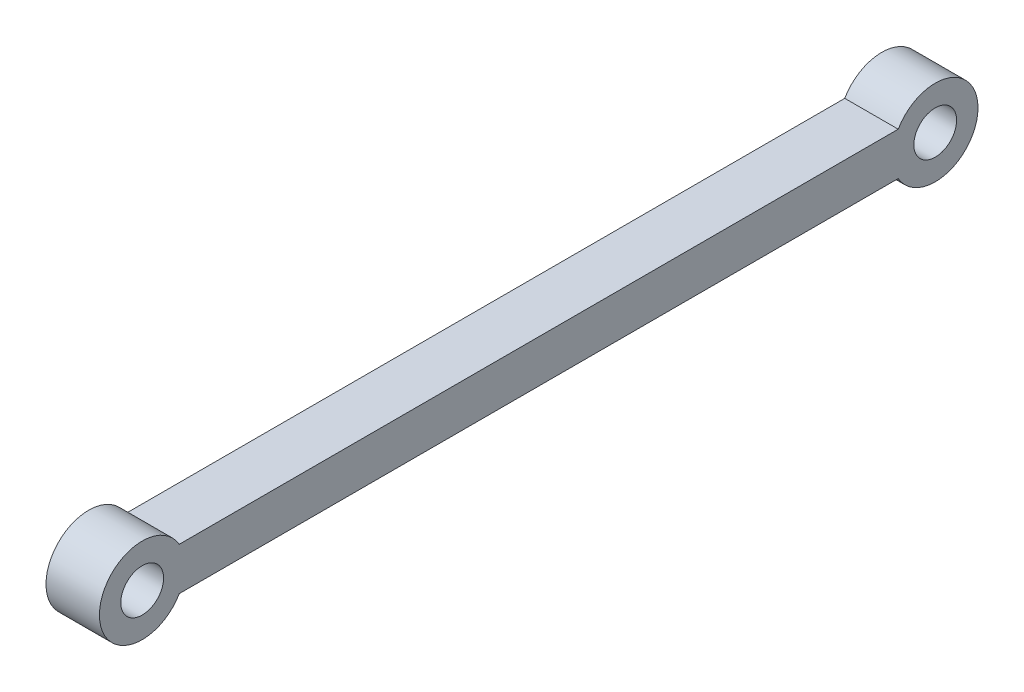
from build123d import *

# Parameters (mm, degrees)
SKETCH1_R           = 1
BOSS_EXTRUDE1_DEPTH = 1.25


with BuildPart() as part:
    # Sketch1 → Boss-Extrude1 (new body, symmetric)
    with BuildSketch(Plane(origin=(0, 0, 0), x_dir=(0, 0, -1), z_dir=(1, 0, 0))):
        with BuildLine():
            Line((-16.815449192, 1), (16.815449192, 1))
            ThreePointArc((16.815449192, 1), (20.5475, 0), (16.815449192, -1))
            Line((16.815449192, -1), (-16.815449192, -1))
            ThreePointArc((-16.815449192, -1), (-20.5475, 0), (-16.815449192, 1))
        make_face()
        with Locations((-18.5475, 0)):
            Circle(SKETCH1_R, mode=Mode.SUBTRACT)
        with Locations((18.5475, 0)):
            Circle(SKETCH1_R, mode=Mode.SUBTRACT)
    extrude(amount=BOSS_EXTRUDE1_DEPTH, both=True)


solid = part.part
